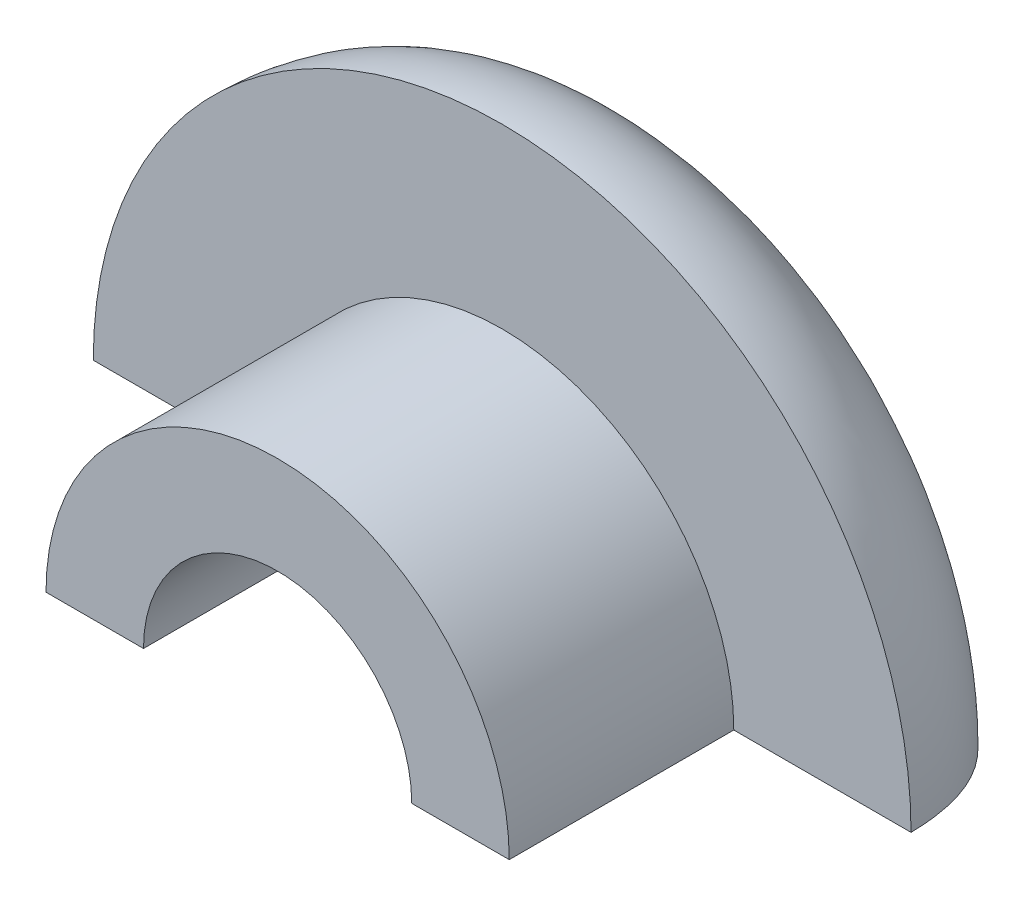
from build123d import *

# Parameters (mm, degrees)
SKETCH1_R               = 4.9784
BOSS_EXTRUDE1_DEPTH     = 4.826
SKETCH2_R               = 2.8829
CUT_EXTRUDE1_DEPTH      = 5.826
CUT_EXTRUDE1_DEPTH_BACK = 7.359654759
SKETCH5_R               = 6.35
CUT_EXTRUDE4_DEPTH      = 0.762
SKETCH8_W               = 25.4
SKETCH8_H               = 25.4
CUT_EXTRUDE5_DEPTH      = 9.7884001


with BuildPart() as part:
    # Sketch1 → Boss-Extrude1 (new body)
    with BuildSketch(Plane.XY):
        Circle(SKETCH1_R)
    extrude(amount=BOSS_EXTRUDE1_DEPTH)

    # Sketch3 → Revolve1 (revolve)
    with BuildSketch(Plane(origin=(0, 0, 0), x_dir=(0, 0, -1), z_dir=(1, 0, 0))):
        with BuildLine():
            Line((0, 0), (6.35, 0))
            add(Edge.make_bspline(
                [(0, 8.7884), (2.795464345, 8.743912966), (3.194527454, 4.557229334), (6.50039289, 2.137437451), (6.35, 0)],
                knots=[0, 0, 0, 0, 0.503113521, 1, 1, 1, 1], degree=3))
            Line((0, 8.7884), (0, 4.9784))
            Line((0, 4.9784), (0, 0))
        make_face()
    revolve(axis=Axis((0, 0, 0), (0, 0, -1)))

    # Sketch2 → Cut-Extrude1 (cut, two sides)
    with BuildSketch(Plane.XY) as cut_extrude1_sk:
        Circle(SKETCH2_R)
    extrude(amount=CUT_EXTRUDE1_DEPTH, mode=Mode.SUBTRACT)
    extrude(cut_extrude1_sk.sketch, amount=-CUT_EXTRUDE1_DEPTH_BACK, mode=Mode.SUBTRACT)

    # Sketch5 → Cut-Extrude4 (cut)
    with BuildSketch(Plane.XY.offset(-5.404994532)):
        Circle(SKETCH5_R)
    extrude(amount=CUT_EXTRUDE4_DEPTH, mode=Mode.SUBTRACT)

    # Sketch8 → Cut-Extrude5 (cut, through all)
    with BuildSketch(Plane(origin=(0, 0, 0), x_dir=(1, 0, 0), z_dir=(0, 1, 0))):
        Rectangle(SKETCH8_W, SKETCH8_H)
    extrude(amount=-CUT_EXTRUDE5_DEPTH, mode=Mode.SUBTRACT)


solid = part.part
